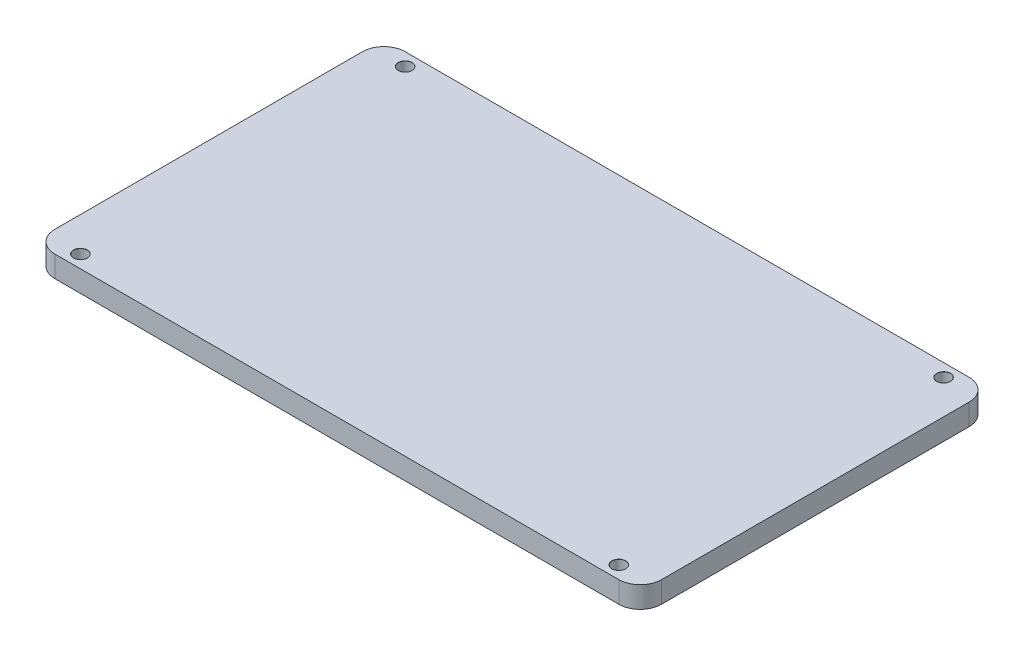
from build123d import *

# Parameters (mm, degrees)
SKETCH1_W                      = 142
SKETCH1_H                      = 82
BOSS_EXTRUDE1_DEPTH            = 5
M3_CLEARANCE_HOLE1_D           = 3.2
M3_CLEARANCE_HOLE1_CSINK_D     = 3.25
M3_CLEARANCE_HOLE1_CSINK_ANGLE = 90
FILLET1_R                      = 5


with BuildPart() as part:
    # Sketch1 → Boss-Extrude1 (new body)
    with BuildSketch(Plane(origin=(0, 0, 0), x_dir=(1, 0, 0), z_dir=(0, 1, 0))):
        Rectangle(SKETCH1_W, SKETCH1_H)
    extrude(amount=BOSS_EXTRUDE1_DEPTH)

    # M3 Clearance Hole1 (through all)
    with Locations(Plane(origin=(0, 5, 0), x_dir=(1, 0, 0), z_dir=(0, 1, 0))):
        with Locations((-63, 38), (-63, -38), (63, 38), (63, -38)):
            CounterSinkHole(M3_CLEARANCE_HOLE1_D / 2, M3_CLEARANCE_HOLE1_CSINK_D / 2, counter_sink_angle=M3_CLEARANCE_HOLE1_CSINK_ANGLE)

    # Fillet1
    fillet1_edges = [part.edges().sort_by_distance(p)[0] for p in [
        (71, 2.5, 41),
        (-71, 2.5, 41),
        (-71, 2.5, -41),
        (71, 2.5, -41),
    ]]
    fillet(fillet1_edges, radius=FILLET1_R)


solid = part.part
